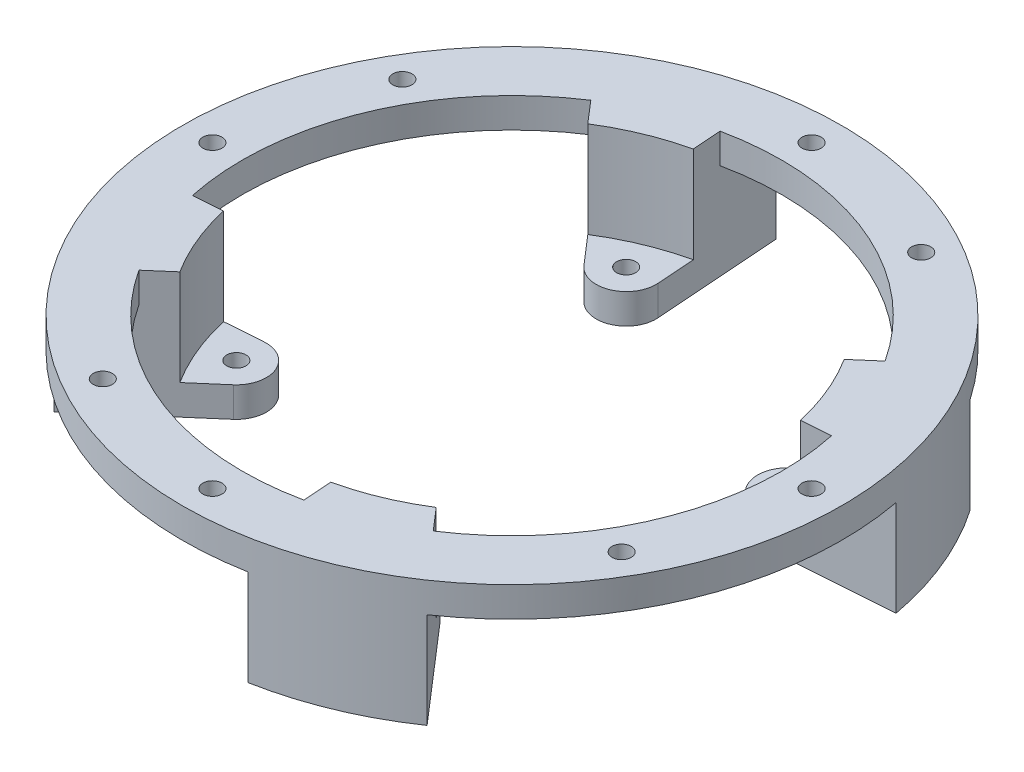
from build123d import *

# Parameters (mm, degrees)
SKETCH1_R           = 55
SKETCH1_R_2         = 1.6
BOSS_EXTRUDE8_DEPTH = 21
CUT_EXTRUDE1_DEPTH  = 16
CUT_EXTRUDE7_START  = 21
SKETCH1_22_R        = 5
SKETCH1_22_R_2      = 1.6
CUT_EXTRUDE7_DEPTH  = 16
SKETCH6_R           = 1.6
CUT_EXTRUDE8_DEPTH  = 81.566742518


with BuildPart() as part:
    # Sketch1 → Boss-Extrude8 (new body)
    with BuildSketch(Plane(origin=(0, 0, 0), x_dir=(1, 0, 0), z_dir=(0, 1, 0))):
        with Locations(Location((0, 0, 0), (0, 0, 90))):
            Circle(SKETCH1_R)
        with BuildLine():
            Line((-24.560877041, 37.706276918), (-17.257446053, 29.262481604))
            ThreePointArc((-17.257446053, 29.262481604), (-11.562365731, 27.91402016), (-8.488842047, 32.894556307))
            Line((-8.488842047, 32.894556307), (-9.295201395, 44.029526809))
            ThreePointArc((-9.295201395, 44.029526809), (17.220754456, 41.574578963), (37.706276918, 24.560877041))
            Line((37.706276918, 24.560877041), (29.262481604, 17.257446053))
            ThreePointArc((29.262481604, 17.257446053), (27.91402016, 11.562365731), (32.894556307, 8.488842047))
            Line((32.894556307, 8.488842047), (44.029526809, 9.295201395))
            ThreePointArc((44.029526809, 9.295201395), (41.574578963, -17.220754456), (24.560877041, -37.706276918))
            Line((24.560877041, -37.706276918), (17.257446053, -29.262481604))
            ThreePointArc((17.257446053, -29.262481604), (11.562365731, -27.91402016), (8.488842047, -32.894556307))
            Line((8.488842047, -32.894556307), (8.94591471, -39.206246783))
            Line((8.94591471, -39.206246783), (9.295201395, -44.029526809))
            ThreePointArc((9.295201395, -44.029526809), (-17.220754456, -41.574578963), (-37.706276918, -24.560877041))
            Line((-37.706276918, -24.560877041), (-34.04871992, -21.39728601))
            Line((-34.04871992, -21.39728601), (-29.262481604, -17.257446053))
            ThreePointArc((-29.262481604, -17.257446053), (-27.91402016, -11.562365731), (-32.894556307, -8.488842047))
            Line((-32.894556307, -8.488842047), (-44.029526809, -9.295201395))
            ThreePointArc((-44.029526809, -9.295201395), (-41.574578963, 17.220754456), (-24.560877041, 37.706276918))
        make_face(mode=Mode.SUBTRACT)
        with Locations(Location((-13.475782892, 32.533417823, 0), (0, 0, 90))):
            Circle(SKETCH1_R_2, mode=Mode.SUBTRACT)
        with Locations(Location((32.533417823, 13.475782892, 0), (0, 0, 90))):
            Circle(SKETCH1_R_2, mode=Mode.SUBTRACT)
        with Locations(Location((-32.533417823, -13.475782892, 0), (0, 0, 90))):
            Circle(SKETCH1_R_2, mode=Mode.SUBTRACT)
        with Locations(Location((13.475782892, -32.533417823, 0), (0, 0, 90))):
            Circle(SKETCH1_R_2, mode=Mode.SUBTRACT)
    extrude(amount=BOSS_EXTRUDE8_DEPTH)

    # Sketch1_15 → Cut-Extrude1 (cut)
    with BuildSketch(Plane(origin=(0, 0, 0), x_dir=(1, 0, 0), z_dir=(0, 1, 0))):
        with BuildLine():
            ThreePointArc((-9.295201395, 44.029526809), (17.220754456, 41.574578963), (37.706276918, 24.560877041))
            Line((37.706276918, 24.560877041), (45.326940374, 31.152343031))
            ThreePointArc((45.326940374, 31.152343031), (21.04758878, 50.813374288), (-10.022953902, 54.079019916))
            Line((-10.022953902, 54.079019916), (-9.295201395, 44.029526809))
        make_face()
        with BuildLine():
            ThreePointArc((-44.029526809, -9.295201395), (-41.574578963, 17.220754456), (-24.560877041, 37.706276918))
            Line((-24.560877041, 37.706276918), (-31.152343031, 45.326940374))
            ThreePointArc((-31.152343031, 45.326940374), (-50.813374288, 21.04758878), (-54.079019916, -10.022953902))
            Line((-54.079019916, -10.022953902), (-44.029526809, -9.295201395))
        make_face()
        with BuildLine():
            Line((54.079019916, 10.022953902), (44.029526809, 9.295201395))
            ThreePointArc((44.029526809, 9.295201395), (41.574578963, -17.220754456), (24.560877041, -37.706276918))
            Line((24.560877041, -37.706276918), (31.152343031, -45.326940374))
            ThreePointArc((31.152343031, -45.326940374), (50.813374288, -21.04758878), (54.079019916, 10.022953902))
        make_face()
        with BuildLine():
            ThreePointArc((9.295201395, -44.029526809), (-17.220754456, -41.574578963), (-37.706276918, -24.560877041))
            Line((-37.706276918, -24.560877041), (-45.326940374, -31.152343031))
            ThreePointArc((-45.326940374, -31.152343031), (-21.04758878, -50.813374288), (10.022953902, -54.079019916))
            Line((10.022953902, -54.079019916), (9.295201395, -44.029526809))
        make_face()
    extrude(amount=CUT_EXTRUDE1_DEPTH, mode=Mode.SUBTRACT)

    # Sketch1_22 → Cut-Extrude7 (cut)
    with BuildSketch(Plane(origin=(0, 0, 0), x_dir=(1, 0, 0), z_dir=(0, 1, 0)).offset(CUT_EXTRUDE7_START)):
        with Locations((13.475782892, -32.533417823)):
            Circle(SKETCH1_22_R)
        with Locations(Location((13.475782892, -32.533417823, 0), (0, 0, 90))):
            Circle(SKETCH1_22_R_2, mode=Mode.SUBTRACT)
        with BuildLine():
            ThreePointArc((15.389200056, -37.152815484), (18.458608875, -35.727285584), (21.39728601, -34.04871992))
            Line((21.39728601, -34.04871992), (17.257446053, -29.262481604))
            ThreePointArc((17.257446053, -29.262481604), (18.16130932, -30.788183712), (18.475782892, -32.533417823))
            ThreePointArc((18.475782892, -32.533417823), (17.633130954, -35.311268987), (15.389200056, -37.152815484))
        make_face()
        with BuildLine():
            ThreePointArc((8.94591471, -39.206246783), (12.210798405, -38.315213416), (15.389200056, -37.152815484))
            ThreePointArc((15.389200056, -37.152815484), (10.849982107, -36.788434889), (8.488842047, -32.894556307))
            Line((8.488842047, -32.894556307), (8.94591471, -39.206246783))
        make_face()
        with BuildLine():
            ThreePointArc((39.206246783, 8.94591471), (38.315213416, 12.210798403), (37.152815486, 15.389200052))
            ThreePointArc((37.152815486, 15.389200052), (37.437344225, 14.451234501), (37.533417823, 13.475782892))
            ThreePointArc((37.533417823, 13.475782892), (36.194407608, 10.070323483), (32.894556307, 8.488842047))
            Line((32.894556307, 8.488842047), (39.206246783, 8.94591471))
        make_face()
        with Locations((32.533417823, 13.475782892)):
            Circle(SKETCH1_22_R)
        with Locations(Location((32.533417823, 13.475782892, 0), (0, 0, 90))):
            Circle(SKETCH1_22_R_2, mode=Mode.SUBTRACT)
        with BuildLine():
            ThreePointArc((37.152815486, 15.389200052), (35.727285585, 18.458608873), (34.04871992, 21.39728601))
            Line((34.04871992, 21.39728601), (29.262481604, 17.257446053))
            ThreePointArc((29.262481604, 17.257446053), (33.685447704, 18.341255855), (37.152815486, 15.389200052))
        make_face()
        with BuildLine():
            Line((-8.488842047, 32.894556307), (-8.94591471, 39.206246783))
            ThreePointArc((-8.94591471, 39.206246783), (-12.210798505, 38.315213384), (-15.38920025, 37.152815404))
            ThreePointArc((-15.38920025, 37.152815404), (-10.849982197, 36.788434944), (-8.488842047, 32.894556307))
        make_face()
        with BuildLine():
            ThreePointArc((-17.257446053, 29.262481604), (-18.34125588, 33.685447599), (-15.38920025, 37.152815404))
            ThreePointArc((-15.38920025, 37.152815404), (-18.458608968, 35.727285536), (-21.39728601, 34.04871992))
            Line((-21.39728601, 34.04871992), (-17.257446053, 29.262481604))
        make_face()
        with Locations((-13.475782892, 32.533417823)):
            Circle(SKETCH1_22_R)
        with Locations(Location((-13.475782892, 32.533417823, 0), (0, 0, 90))):
            Circle(SKETCH1_22_R_2, mode=Mode.SUBTRACT)
        with Locations((-32.533417823, -13.475782892)):
            Circle(SKETCH1_22_R)
        with Locations(Location((-32.533417823, -13.475782892, 0), (0, 0, 90))):
            Circle(SKETCH1_22_R_2, mode=Mode.SUBTRACT)
        with BuildLine():
            ThreePointArc((-29.262481604, -17.257446053), (-33.685447701, -18.341255856), (-37.152815484, -15.389200057))
            ThreePointArc((-37.152815484, -15.389200057), (-35.727285584, -18.458608875), (-34.04871992, -21.39728601))
            Line((-34.04871992, -21.39728601), (-29.262481604, -17.257446053))
        make_face()
        with BuildLine():
            Line((-32.894556307, -8.488842047), (-39.206246783, -8.94591471))
            ThreePointArc((-39.206246783, -8.94591471), (-38.315213416, -12.210798405), (-37.152815484, -15.389200057))
            ThreePointArc((-37.152815484, -15.389200057), (-36.788434889, -10.849982108), (-32.894556307, -8.488842047))
        make_face()
    extrude(amount=-CUT_EXTRUDE7_DEPTH, mode=Mode.SUBTRACT)

    # Sketch6 → Cut-Extrude8 (cut, through all)
    with BuildSketch(Plane(origin=(0, 21, 0), x_dir=(1, 0, 0), z_dir=(0, 1, 0))):
        with Locations(Location((0, 50, 0), (0, 0, 270))):
            Circle(SKETCH6_R)
        with Locations(Location((25, 43.301270189, 0), (0, 0, 270))):
            Circle(SKETCH6_R)
        with Locations(Location((50, 0, 0), (0, 0, 270))):
            Circle(SKETCH6_R)
        with Locations(Location((43.301270189, -25, 0), (0, 0, 270))):
            Circle(SKETCH6_R)
        with Locations(Location((0, -50, 0), (0, 0, 270))):
            Circle(SKETCH6_R)
        with Locations(Location((-25, -43.301270189, 0), (0, 0, 270))):
            Circle(SKETCH6_R)
        with Locations(Location((-50, 0, 0), (0, 0, 270))):
            Circle(SKETCH6_R)
        with Locations(Location((-43.301270189, 25, 0), (0, 0, 270))):
            Circle(SKETCH6_R)
    extrude(amount=-CUT_EXTRUDE8_DEPTH, mode=Mode.SUBTRACT)


solid = part.part
